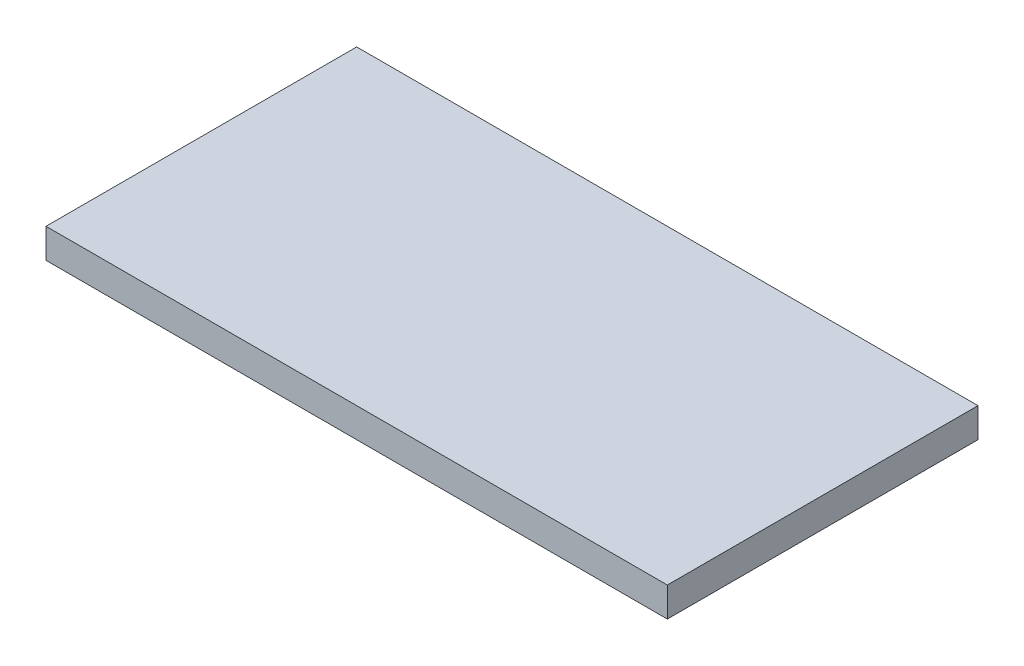
from build123d import *

# Parameters (mm, degrees)
SKETCH1_W           = 400
SKETCH1_H           = 200
BOSS_EXTRUDE1_DEPTH = 19


with BuildPart() as part:
    # Sketch1 → Boss-Extrude1 (new body)
    with BuildSketch(Plane(origin=(0, 0, 0), x_dir=(1, 0, 0), z_dir=(0, 1, 0))):
        with Locations((200, 100)):
            Rectangle(SKETCH1_W, SKETCH1_H)
    extrude(amount=BOSS_EXTRUDE1_DEPTH)


solid = part.part
